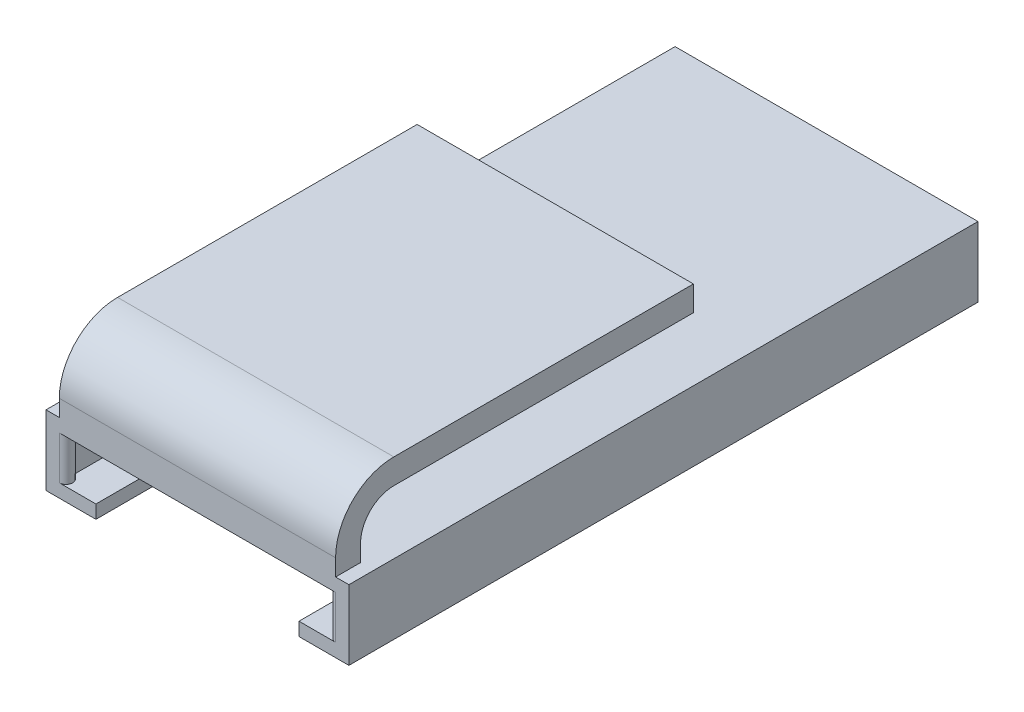
from build123d import *

# Parameters (mm, degrees)
SKETCH1_W           = 36.4
SKETCH1_H           = 75.6
SKETCH1_W_2         = 33.2
SKETCH1_H_2         = 72.4
BOSS_EXTRUDE1_DEPTH = 5.2
SKETCH2_W           = 36.4
SKETCH2_H           = 75.6
BOSS_EXTRUDE2_DEPTH = 1.6
BOSS_EXTRUDE3_START = 5.2
SKETCH2_2_W         = 36.4
SKETCH2_2_H         = 75.6
BOSS_EXTRUDE3_DEPTH = 1.6
CUT_EXTRUDE1_START  = -1.6
CUT_EXTRUDE1_DEPTH  = 5.2
BOSS_EXTRUDE4_START = -1.6
BOSS_EXTRUDE4_DEPTH = 33.2
CUT_EXTRUDE2_DEPTH  = 2
FILLET1_R           = 7


with BuildPart() as part:
    # Sketch1 → Boss-Extrude1 (new body)
    with BuildSketch(Plane(origin=(0, 0, 0), x_dir=(1, 0, 0), z_dir=(0, 1, 0))):
        with Locations((16.6, 36.2)):
            Rectangle(SKETCH1_W, SKETCH1_H)
        with Locations((16.6, 36.2)):
            Rectangle(SKETCH1_W_2, SKETCH1_H_2, mode=Mode.SUBTRACT)
    extrude(amount=BOSS_EXTRUDE1_DEPTH)

    # Sketch2 → Boss-Extrude2 (add)
    with BuildSketch(Plane(origin=(0, 0, 0), x_dir=(1, 0, 0), z_dir=(0, 1, 0))):
        with Locations((16.6, 36.2)):
            Rectangle(SKETCH2_W, SKETCH2_H)
    extrude(amount=-BOSS_EXTRUDE2_DEPTH)

    # Sketch2_2 → Boss-Extrude3 (add)
    with BuildSketch(Plane(origin=(0, 0, 0), x_dir=(1, 0, 0), z_dir=(0, 1, 0)).offset(BOSS_EXTRUDE3_START)):
        with Locations((16.6, 36.2)):
            Rectangle(SKETCH2_2_W, SKETCH2_2_H)
    extrude(amount=BOSS_EXTRUDE3_DEPTH)

    # Sketch3 → Cut-Extrude1 (cut)
    with BuildSketch(Plane(origin=(0, 6.8, 0), x_dir=(1, 0, 0), z_dir=(0, 1, 0)).offset(CUT_EXTRUDE1_START)):
        with BuildLine():
            Line((0, 0), (33.2, 0))
            ThreePointArc((33.2, 0), (32.4, -0.8), (33.2, -1.6))
            Line((33.2, -1.6), (0, -1.6))
            ThreePointArc((0, -1.6), (0.8, -0.8), (0, 0))
        make_face()
    extrude(amount=-CUT_EXTRUDE1_DEPTH, mode=Mode.SUBTRACT)

    # Sketch4 → Boss-Extrude4 (add)
    with BuildSketch(Plane(origin=(34.8, 0, 0), x_dir=(0, 0, -1), z_dir=(1, 0, 0)).offset(BOSS_EXTRUDE4_START)):
        with BuildLine():
            Line((1.4, 6.8), (1.4, 8.8))
            ThreePointArc((1.4, 8.8), (2.571572875, 11.628427125), (5.4, 12.8))
            Line((5.4, 12.8), (41.4, 12.8))
            Line((41.4, 12.8), (41.4, 15.8))
            Line((41.4, 15.8), (-1.6, 15.8))
            Line((-1.6, 15.8), (-1.6, 6.8))
            Line((-1.6, 6.8), (1.4, 6.8))
        make_face()
    extrude(amount=-BOSS_EXTRUDE4_DEPTH)

    # Sketch5 → Cut-Extrude2 (cut)
    with BuildSketch(Plane.XZ.offset(1.6)):
        with BuildLine():
            Line((4.4, 1.6), (28.8, 1.6))
            Line((28.8, 1.6), (28.8, -8.4))
            ThreePointArc((28.8, -8.4), (16.6, -20.6), (4.4, -8.4))
            Line((4.4, -8.4), (4.4, 1.6))
        make_face()
    extrude(amount=-CUT_EXTRUDE2_DEPTH, mode=Mode.SUBTRACT)

    # Fillet1
    fillet1_edges = [part.edges().sort_by_distance(p)[0] for p in [
        (16.6, 15.8, 1.6),
    ]]
    fillet(fillet1_edges, radius=FILLET1_R)


solid = part.part
